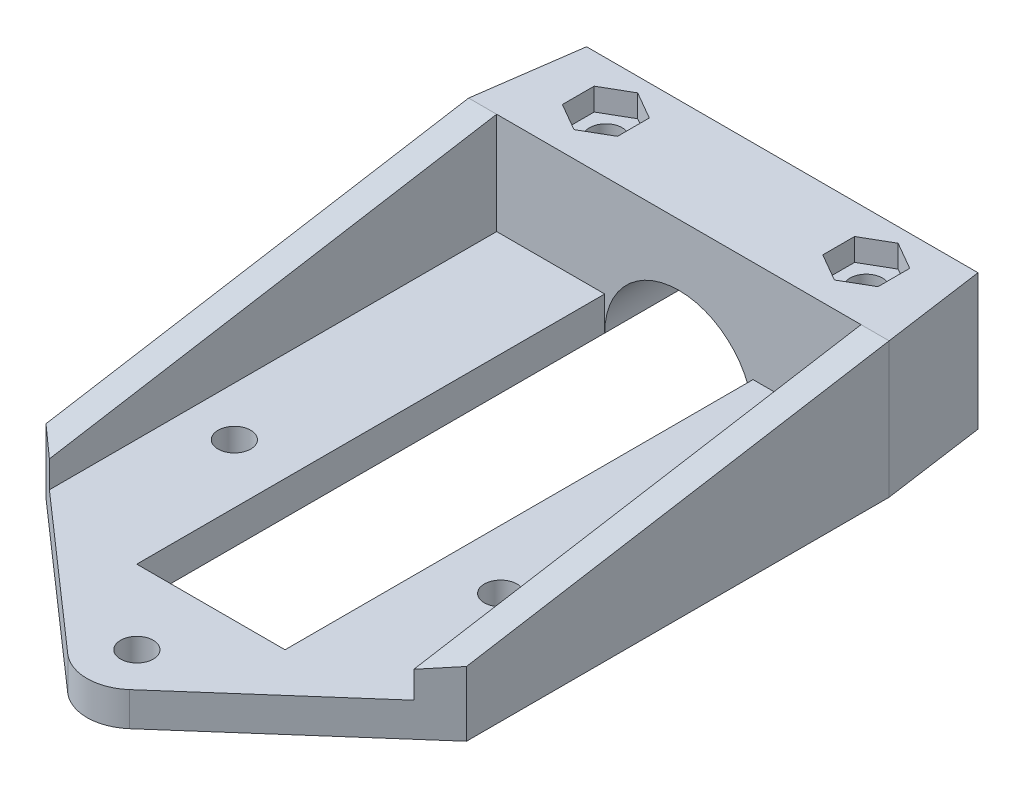
from build123d import *

# Parameters (mm, degrees)
BOSS_EXTRUDE3_DEPTH              = 14.5
SKETCH8_R                        = 7.935
CUT_EXTRUDE3_DEPTH               = 88
CUT_EXTRUDE9_DEPTH               = 2.4
F_39_0_13779528_DIAMETER_HOLE1_D = 3.500000112
CUT_EXTRUDE10_DEPTH              = 22.4
CUT_EXTRUDE11_DEPTH              = 2.4
BOSS_EXTRUDE7_DEPTH              = 3.625
F_39_0_13779528_DIAMETER_HOLE2_D = 3.500000112
BOSS_EXTRUDE10_DEPTH             = 3
BOSS_EXTRUDE11_DEPTH             = 3
CUT_EXTRUDE14_DEPTH              = 13
CUT_EXTRUDE15_DEPTH              = 13
FILLET1_R                        = 5


with BuildPart() as part:
    # Sketch6 → Boss-Extrude3 (new body)
    with BuildSketch(Plane(origin=(0, 0, 0), x_dir=(1, 0, 0), z_dir=(0, 1, 0))):
        Polygon((-16.836914056, 5.783353512), (13.163085944, 5.783353512), (20.663085944, -47.581919406), (-24.336914056, -47.581919406), align=None)
    extrude(amount=BOSS_EXTRUDE3_DEPTH)

    # Sketch8 → Cut-Extrude3 (cut)
    with BuildSketch(Plane.XY.offset(47.581919406)):
        with Locations((-1.836914056, 0)):
            Circle(SKETCH8_R)
    extrude(amount=-CUT_EXTRUDE3_DEPTH, mode=Mode.SUBTRACT)

    # Sketch18 → Cut-Extrude9 (cut)
    with BuildSketch(Plane(origin=(0, 14.5, 0), x_dir=(1, 0, 0), z_dir=(0, 1, 0))):
        Polygon((-15.771819769, -44.868285994), (-12.821819769, -43.1651027), (-12.821819769, -39.758736112), (-15.771819769, -38.055552818), (-18.721819769, -39.758736112), (-18.721819769, -43.1651027), align=None)
        Polygon((12.097991657, -44.868285994), (15.047991657, -43.1651027), (15.047991657, -39.758736112), (12.097991657, -38.055552818), (9.147991657, -39.758736112), (9.147991657, -43.1651027), align=None)
        Polygon((11.389331688, -26.016021021), (14.389331688, -24.283970214), (14.389331688, -20.819868599), (11.389331688, -19.087817791), (8.389331688, -20.819868599), (8.389331688, -24.283970214), align=None)
        Polygon((-15.0631598, -26.016021021), (-12.0631598, -24.283970214), (-12.0631598, -20.819868599), (-15.0631598, -19.087817791), (-18.0631598, -20.819868599), (-18.0631598, -24.283970214), align=None)
    extrude(amount=-CUT_EXTRUDE9_DEPTH, mode=Mode.SUBTRACT)

    # #39 (0.13779528) Diameter Hole1 (through all)
    with Locations(Plane(origin=(-15.0631598, 14.5, 22.551919406), x_dir=(0, 0, 1), z_dir=(0, 1, 0))):
        with Locations((0, 0), (0, 26.452491488), (18.91, -0.708659969), (18.91, 27.161151457)):
            Hole(F_39_0_13779528_DIAMETER_HOLE1_D / 2)

    # Sketch22 → Cut-Extrude10 (cut)
    with BuildSketch(Plane(origin=(0, 14.5, 0), x_dir=(1, 0, 0), z_dir=(0, 1, 0))):
        Polygon((-22.781301734, -36.51316259), (19.107473622, -36.51316259), (13.163085944, 5.783353512), (-16.836914056, 5.783353512), align=None)
    extrude(amount=-CUT_EXTRUDE10_DEPTH, mode=Mode.SUBTRACT)

    # Sketch24 → Cut-Extrude11 (cut)
    with BuildSketch(Plane.XZ):
        Polygon((-15.771819769, 38.055552818), (-12.821819769, 39.758736112), (-12.821819769, 43.1651027), (-15.771819769, 44.868285994), (-18.721819769, 43.1651027), (-18.721819769, 39.758736112), align=None)
        Polygon((12.097991657, 38.055552818), (15.047991657, 39.758736112), (15.047991657, 43.1651027), (12.097991657, 44.868285994), (9.147991657, 43.1651027), (9.147991657, 39.758736112), align=None)
    extrude(amount=-CUT_EXTRUDE11_DEPTH, mode=Mode.SUBTRACT)

    # Sketch27 → Boss-Extrude7 (add)
    with BuildSketch(Plane(origin=(0, 0, 0), x_dir=(1, 0, 0), z_dir=(0, 1, 0))):
        Polygon((6.098085944, -47.581919406), (20.663085944, -47.581919406), (20.663085944, -112.581919406), (-9.771914056, -112.581919406), (-24.336914056, -112.581919406), (-24.336914056, -47.581919406), (-9.771914056, -47.581919406), (-9.771914056, -97.661919406), (6.098085944, -97.661919406), align=None)
    extrude(amount=BOSS_EXTRUDE7_DEPTH)

    # #39 (0.13779528) Diameter Hole2 (through all)
    with Locations(Plane(origin=(-16.086914056, 3.625, 80.900195398), x_dir=(0, 0, 1), z_dir=(0, 1, 0))):
        with Locations((0, 0), (24.681724008, 14.25), (0, 28.5)):
            Hole(F_39_0_13779528_DIAMETER_HOLE2_D / 2)

    # Sketch39 → Boss-Extrude10 (add)
    with BuildSketch(Plane(origin=(20.663085944, 0, 0), x_dir=(0, 0, -1), z_dir=(1, 0, 0))):
        Polygon((-47.581919406, 14.5), (-112.581919406, 3.625), (-47.581919406, 3.625), align=None)
    extrude(amount=-BOSS_EXTRUDE10_DEPTH)

    # Sketch40 → Boss-Extrude11 (add)
    with BuildSketch(Plane.ZY.offset(24.336914056)):
        Polygon((47.581919406, 14.5), (112.581919406, 3.625), (47.581919406, 3.625), align=None)
    extrude(amount=-BOSS_EXTRUDE11_DEPTH)

    # Sketch43 → Cut-Extrude14 (cut)
    with BuildSketch(Plane.XZ):
        Polygon((-1.836914056, 112.581919406), (-24.336914056, 112.581919406), (-24.336914056, 92.810231668), align=None)
    extrude(amount=-CUT_EXTRUDE14_DEPTH, mode=Mode.SUBTRACT)

    # Sketch44 → Cut-Extrude15 (cut)
    with BuildSketch(Plane.XZ):
        Polygon((20.663085944, 92.810231668), (20.663085944, 112.581919406), (-1.836914056, 112.581919406), align=None)
    extrude(amount=-CUT_EXTRUDE15_DEPTH, mode=Mode.SUBTRACT)

    # Fillet1
    fillet1_edges = [part.edges().sort_by_distance(p)[0] for p in [
        (-1.836914056, 1.8125, 112.581919406),
    ]]
    fillet(fillet1_edges, radius=FILLET1_R)


solid = part.part
